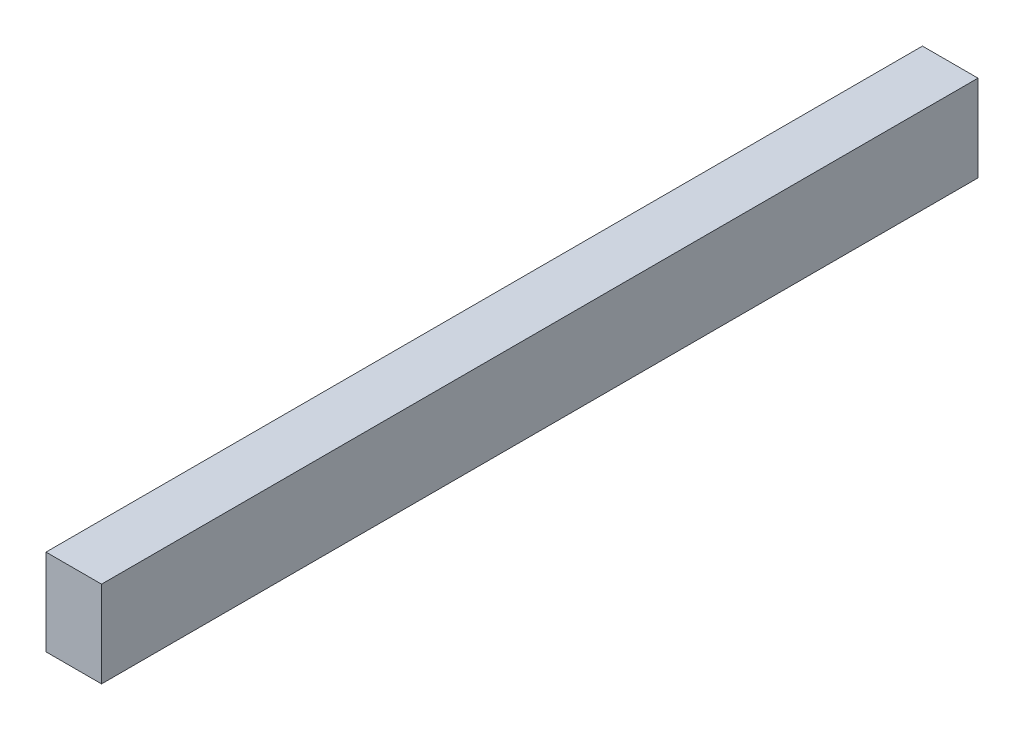
from build123d import *

# Parameters (mm, degrees)
SKETCH1_W           = 45
SKETCH1_H           = 70
BOSS_EXTRUDE1_DEPTH = 710


with BuildPart() as part:
    # Sketch1 → Boss-Extrude1 (new body)
    with BuildSketch(Plane.XY):
        with Locations((22.5, -35)):
            Rectangle(SKETCH1_W, SKETCH1_H)
    extrude(amount=BOSS_EXTRUDE1_DEPTH)


solid = part.part
